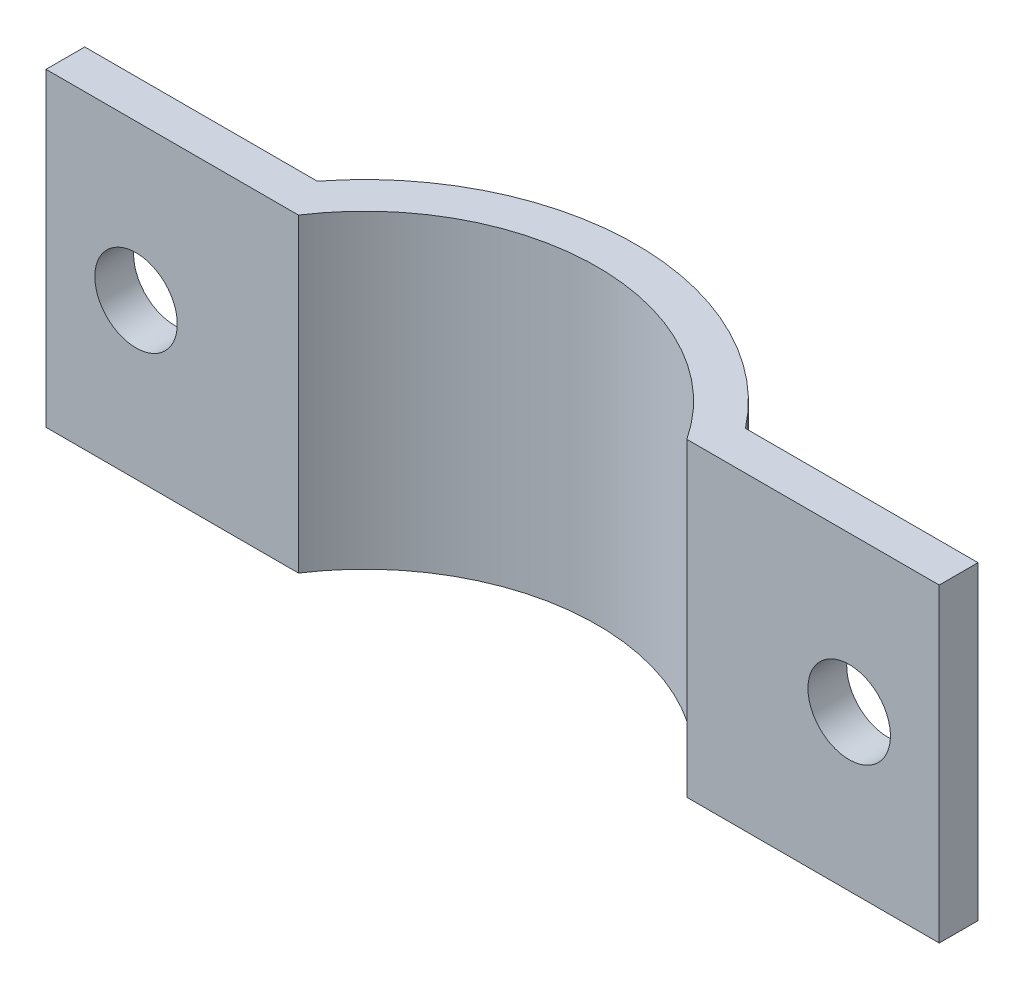
from build123d import *

# Parameters (mm, degrees)
SKETCH1_R           = 19.05
BOSS_EXTRUDE1_DEPTH = 25.4
SKETCH2_R           = 3.3782
CUT_EXTRUDE1_DEPTH  = 36.8775
SKETCH3_W           = 85.242997218
SKETCH3_H           = 34.152222548
CUT_EXTRUDE2_DEPTH  = 26.4


with BuildPart() as part:
    # Sketch1 → Boss-Extrude1 (new body)
    with BuildSketch(Plane(origin=(0, 0, 0), x_dir=(1, 0, 0), z_dir=(0, 1, 0))):
        with BuildLine():
            Line((36.587384889, 13.6525), (17.537384889, 13.6525))
            ThreePointArc((17.537384889, 13.6525), (0, 22.225), (-17.537384889, 13.6525))
            Line((-17.537384889, 13.6525), (-36.587384889, 13.6525))
            Line((-36.587384889, 13.6525), (-36.587384889, 4.1275))
            Line((-36.587384889, 4.1275), (-21.838369187, 4.1275))
            ThreePointArc((-21.838369187, 4.1275), (0, -22.225), (21.838369187, 4.1275))
            Line((21.838369187, 4.1275), (36.587384889, 4.1275))
            Line((36.587384889, 4.1275), (36.587384889, 13.6525))
        make_face()
        Circle(SKETCH1_R, mode=Mode.SUBTRACT)
    extrude(amount=BOSS_EXTRUDE1_DEPTH)

    # Sketch2 → Cut-Extrude1 (cut, through all)
    with BuildSketch(Plane(origin=(0, 0, -13.6525), x_dir=(-1, 0, 0), z_dir=(0, 0, -1))):
        with Locations((29.21, 12.7)):
            Circle(SKETCH2_R)
        with Locations((-29.21, 12.7)):
            Circle(SKETCH2_R)
    extrude(amount=-CUT_EXTRUDE1_DEPTH, mode=Mode.SUBTRACT)

    # Sketch3 → Cut-Extrude2 (cut, through all)
    with BuildSketch(Plane(origin=(0, 25.4, 0), x_dir=(1, 0, 0), z_dir=(0, 1, 0))):
        with Locations((-0.146640147, -6.598611274)):
            Rectangle(SKETCH3_W, SKETCH3_H)
    extrude(amount=-CUT_EXTRUDE2_DEPTH, mode=Mode.SUBTRACT)


solid = part.part
